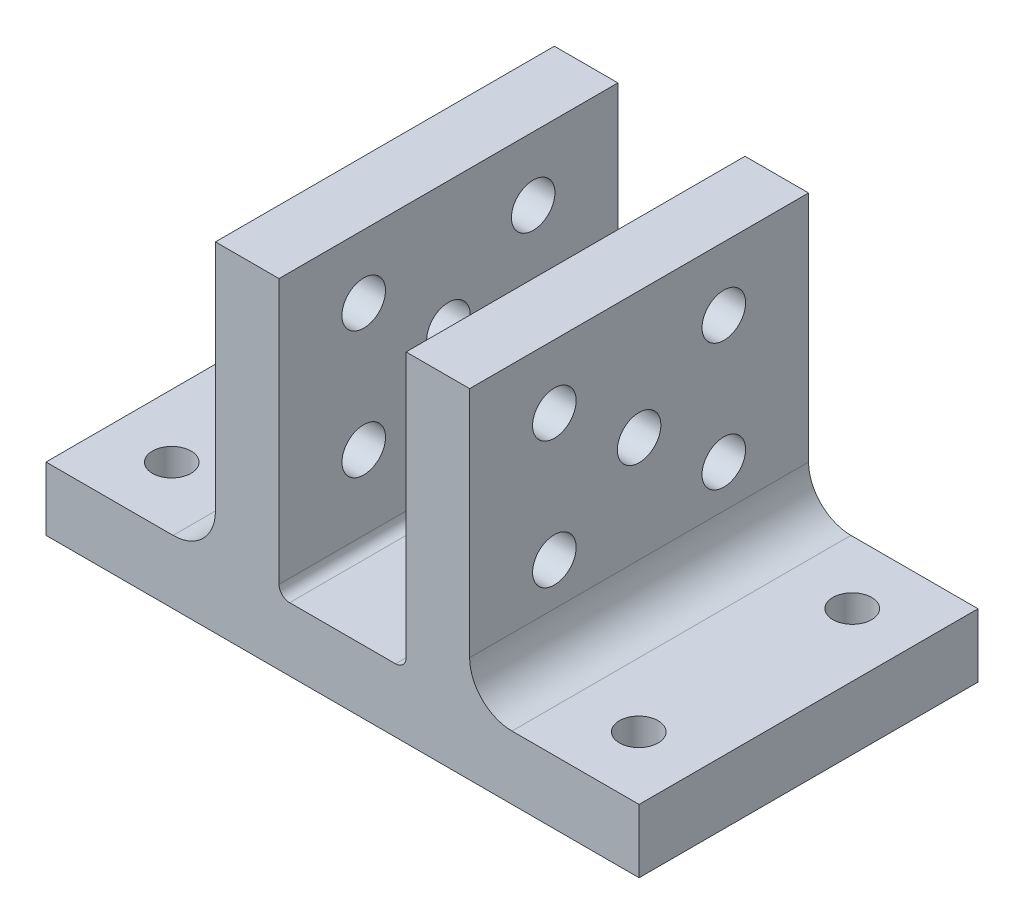
from build123d import *

# Parameters (mm, degrees)
BOSS_EXTRUDE1_DEPTH          = 25.4
FILLET1_R                    = 0.79375
M2_5_CLEARANCE_HOLE1_D       = 2.9
M2_5X0_45_TAPPED_HOLE1_D     = 2.05
M2_5X0_45_TAPPED_HOLE1_DEPTH = 3.956117865
M2_5X0_45_TAPPED_HOLE1_TIP   = 0.615882135
F_4_CLEARANCE_HOLE1_D        = 3.2639


with BuildPart() as part:
    # Sketch1 → Boss-Extrude1 (new body)
    with BuildSketch(Plane.XY):
        with BuildLine():
            Line((-4.7625, 2.38125), (4.7625, 2.38125))
            Line((4.7625, 2.38125), (4.7625, 23.01875))
            Line((4.7625, 23.01875), (9.525, 23.01875))
            Line((9.525, 23.01875), (9.525, 5.55625))
            ThreePointArc((9.525, 5.55625), (10.45493597, 3.31118597), (12.7, 2.38125))
            Line((12.7, 2.38125), (22.225, 2.38125))
            Line((22.225, 2.38125), (22.225, -2.38125))
            Line((22.225, -2.38125), (-22.225, -2.38125))
            Line((-22.225, -2.38125), (-22.225, 2.38125))
            Line((-22.225, 2.38125), (-12.7, 2.38125))
            ThreePointArc((-12.7, 2.38125), (-10.45493597, 3.31118597), (-9.525, 5.55625))
            Line((-9.525, 5.55625), (-9.525, 23.01875))
            Line((-9.525, 23.01875), (-4.7625, 23.01875))
            Line((-4.7625, 23.01875), (-4.7625, 2.38125))
        make_face()
    extrude(amount=BOSS_EXTRUDE1_DEPTH)

    # Fillet1
    fillet1_edges = [part.edges().sort_by_distance(p)[0] for p in [
        (-4.7625, 2.38125, 12.7),
        (4.7625, 2.38125, 12.7),
    ]]
    fillet(fillet1_edges, radius=FILLET1_R)

    # M2.5 Clearance Hole1 (through all)
    with Locations(Plane(origin=(0, 2.38125, 0), x_dir=(1, 0, 0), z_dir=(0, 1, 0))):
        with Locations((17.5006, -4.70027), (17.5006, -20.69973), (-17.5006, -20.69973), (-17.5006, -4.70027)):
            Hole(M2_5_CLEARANCE_HOLE1_D / 2)

    # M2.5x0.45 Tapped Hole1
    with Locations(Plane(origin=(0, -2.38125, 0), x_dir=(-1, 0, 0), z_dir=(0, -1, 0))):
        with Locations((-7.78002, -4.70027), (7.78002, -4.70027), (7.78002, -20.69973), (-7.78002, -20.69973)):
            Hole(M2_5X0_45_TAPPED_HOLE1_D / 2, depth=M2_5X0_45_TAPPED_HOLE1_DEPTH)
            with Locations((0, 0, -(M2_5X0_45_TAPPED_HOLE1_DEPTH + M2_5X0_45_TAPPED_HOLE1_TIP / 2))):  # 118° drill point
                Cone(0, M2_5X0_45_TAPPED_HOLE1_D / 2, M2_5X0_45_TAPPED_HOLE1_TIP, mode=Mode.SUBTRACT)

    # #4 Clearance Hole1 (through all)
    with Locations(Plane.ZY.offset(9.525)):
        with Locations((6.35, 18.25625), (19.05, 18.25625), (19.05, 8.73125), (6.35, 8.73125), (12.7, 13.49375)):
            Hole(F_4_CLEARANCE_HOLE1_D / 2)


solid = part.part
